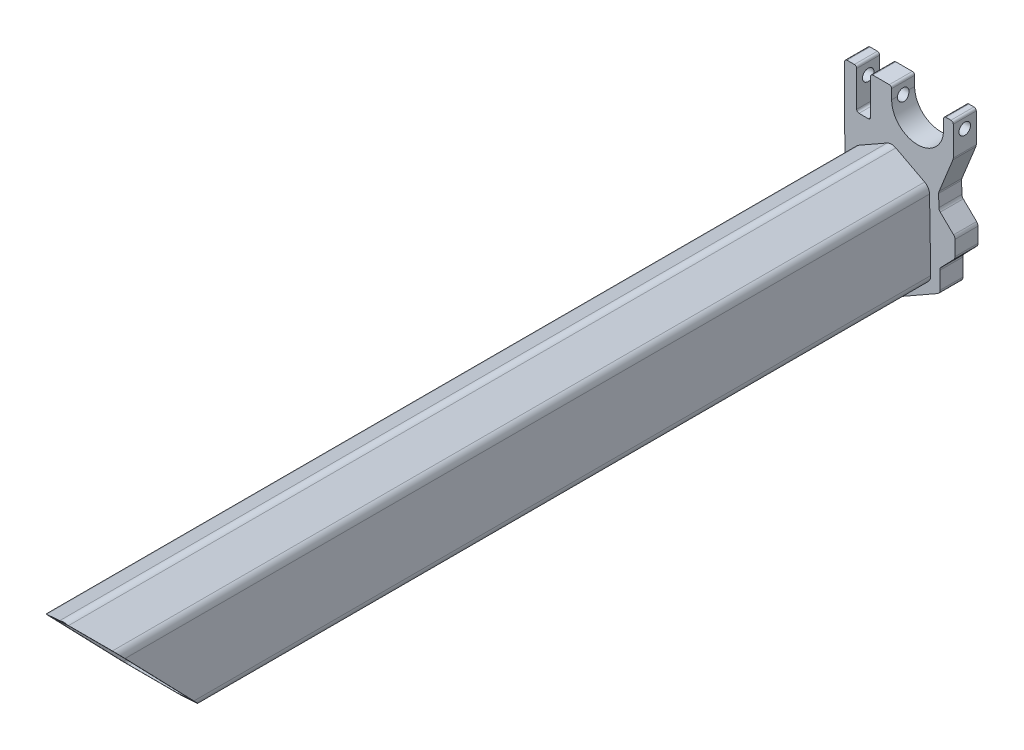
from build123d import *

# Parameters (mm, degrees)
BOSS_EXTRUDE1_DEPTH     = 5
BOSS_EXTRUDE2_DEPTH     = 180
SKETCH3_R               = 1.25
CUT_EXTRUDE1_DEPTH      = 180
CUT_EXTRUDE1_DEPTH_BACK = 180


with BuildPart() as part:
    # Sketch1 → Boss-Extrude1 (new body)
    with BuildSketch(Plane.XY):
        with BuildLine():
            Line((176.569505492, 187.840095713), (176.899877953, 168.242969935))
            ThreePointArc((176.899877953, 168.242969935), (177.048290864, 167.735381874), (177.434829134, 167.374466097))
            Line((177.434829134, 167.374466097), (186.718316852, 162.499660601))
            ThreePointArc((186.718316852, 162.499660601), (187.200079416, 162.385162323), (187.67770885, 162.515834233))
            Line((187.67770885, 162.515834233), (196.791607056, 167.700786723))
            ThreePointArc((196.791607056, 167.700786723), (197.16576035, 168.074526398), (197.296979738, 168.586828559))
            Line((197.296979738, 168.586828559), (197.234516514, 172.292039484))
            ThreePointArc((197.234516514, 172.292039484), (197.304175726, 172.675951622), (197.515449261, 173.003982761))
            Line((197.515449261, 173.003982761), (200.266782587, 175.849671866))
            ThreePointArc((200.266782587, 175.849671866), (200.474929456, 176.169876136), (200.547857403, 176.544759328))
            Line((200.547857403, 176.544759328), (200.547857403, 179.779238985))
            ThreePointArc((200.547857403, 179.779238985), (200.468478786, 180.169695473), (200.242944865, 180.498164169))
            Line((200.242944865, 180.498164169), (197.341824739, 183.303090564))
            ThreePointArc((197.341824739, 183.303090564), (197.119614365, 183.623813941), (197.037054271, 184.005159933))
            Line((197.037054271, 184.005159933), (196.992324343, 186.658462241))
            ThreePointArc((196.992324343, 186.658462241), (197.009048268, 186.858204702), (197.065271311, 187.050599374))
            Line((197.065271311, 187.050599374), (200.096416454, 194.537254131))
            ThreePointArc((200.096416454, 194.537254131), (200.151063173, 194.721369242), (200.169505492, 194.912535449))
            Line((200.169505492, 194.912535449), (200.169505492, 201.285162323))
            ThreePointArc((200.169505492, 201.285162323), (200.023058882, 201.638715714), (199.669505492, 201.785162323))
            Line((199.669505492, 201.785162323), (198.569505492, 201.785162323))
            ThreePointArc((198.569505492, 201.785162323), (198.215952101, 201.638715714), (198.069505492, 201.285162323))
            Line((198.069505492, 201.285162323), (198.069505492, 199.185162323))
            ThreePointArc((198.069505492, 199.185162323), (192.419505492, 193.535162323), (186.769505492, 199.185162323))
            Line((186.769505492, 199.185162323), (186.769505492, 201.285162323))
            ThreePointArc((186.769505492, 201.285162323), (186.623058882, 201.638715714), (186.269505492, 201.785162323))
            Line((186.269505492, 201.785162323), (182.669505492, 201.785162323))
            ThreePointArc((182.669505492, 201.785162323), (182.315952101, 201.638715714), (182.169505492, 201.285162323))
            Line((182.169505492, 201.285162323), (182.169505492, 193.585162323))
            ThreePointArc((182.169505492, 193.585162323), (182.023058882, 193.231608933), (181.669505492, 193.085162323))
            Line((181.669505492, 193.085162323), (179.669505492, 193.085162323))
            ThreePointArc((179.669505492, 193.085162323), (179.315952101, 193.231608933), (179.169505492, 193.585162323))
            Line((179.169505492, 193.585162323), (179.169505492, 201.285162323))
            ThreePointArc((179.169505492, 201.285162323), (179.023058882, 201.638715714), (178.669505492, 201.785162323))
            Line((178.669505492, 201.785162323), (177.069505492, 201.785162323))
            ThreePointArc((177.069505492, 201.785162323), (176.715952101, 201.638715714), (176.569505492, 201.285162323))
            Line((176.569505492, 201.285162323), (176.569505492, 187.840095713))
        make_face()
        with BuildLine():
            Line((186.260276974, 189.669797845), (180.118302096, 186.175590732))
            ThreePointArc((180.118302096, 186.175590732), (179.744148802, 185.801851058), (179.612929414, 185.289548897))
            Line((179.612929414, 185.289548897), (179.869468758, 170.072076543))
            ThreePointArc((179.869468758, 170.072076543), (180.017881669, 169.564488482), (180.404419939, 169.203572705))
            Line((180.404419939, 169.203572705), (186.660683401, 165.918377698))
            ThreePointArc((186.660683401, 165.918377698), (187.142445966, 165.803879419), (187.6200754, 165.934551329))
            Line((187.6200754, 165.934551329), (193.762050278, 169.428758442))
            ThreePointArc((193.762050278, 169.428758442), (194.136203572, 169.802498117), (194.26742296, 170.314800278))
            Line((194.26742296, 170.314800278), (194.010883616, 185.532272632))
            ThreePointArc((194.010883616, 185.532272632), (193.862470704, 186.039860693), (193.475932435, 186.400776469))
            Line((193.475932435, 186.400776469), (187.219668972, 189.685971477))
            ThreePointArc((187.219668972, 189.685971477), (186.737906408, 189.800469755), (186.260276974, 189.669797845))
        make_face(mode=Mode.SUBTRACT)
    extrude(amount=BOSS_EXTRUDE1_DEPTH)

    # Sketch2 → Boss-Extrude2 (add)
    with BuildSketch(Plane.XY.offset(5)):
        with BuildLine():
            Line((185.765791725, 190.538983866), (179.623816847, 187.044776753))
            ThreePointArc((179.623816847, 187.044776753), (178.875510259, 186.297297404), (178.613071484, 185.272693082))
            Line((178.613071484, 185.272693082), (178.869610827, 170.055220728))
            ThreePointArc((178.869610827, 170.055220728), (179.16643665, 169.040044606), (179.93951319, 168.318213053))
            Line((179.93951319, 168.318213053), (186.195776652, 165.033018045))
            ThreePointArc((186.195776652, 165.033018045), (187.159301781, 164.804021489), (188.114560649, 165.065365309))
            Line((188.114560649, 165.065365309), (194.256535527, 168.559572421))
            ThreePointArc((194.256535527, 168.559572421), (195.004842115, 169.307051771), (195.26728089, 170.331656093))
            Line((195.26728089, 170.331656093), (195.010741546, 185.549128447))
            ThreePointArc((195.010741546, 185.549128447), (194.713915724, 186.564304569), (193.940839184, 187.286136122))
            Line((193.940839184, 187.286136122), (187.684575722, 190.57133113))
            ThreePointArc((187.684575722, 190.57133113), (186.721050593, 190.800327686), (185.765791725, 190.538983866))
        make_face()
        with BuildLine():
            Line((186.260276974, 189.669797845), (180.118302096, 186.175590732))
            ThreePointArc((180.118302096, 186.175590732), (179.744148802, 185.801851058), (179.612929414, 185.289548897))
            Line((179.612929414, 185.289548897), (179.869468758, 170.072076543))
            ThreePointArc((179.869468758, 170.072076543), (180.017881669, 169.564488482), (180.404419939, 169.203572705))
            Line((180.404419939, 169.203572705), (186.660683401, 165.918377698))
            ThreePointArc((186.660683401, 165.918377698), (187.142445966, 165.803879419), (187.6200754, 165.934551329))
            Line((187.6200754, 165.934551329), (193.762050278, 169.428758442))
            ThreePointArc((193.762050278, 169.428758442), (194.136203572, 169.802498117), (194.26742296, 170.314800278))
            Line((194.26742296, 170.314800278), (194.010883616, 185.532272632))
            ThreePointArc((194.010883616, 185.532272632), (193.862470704, 186.039860693), (193.475932435, 186.400776469))
            Line((193.475932435, 186.400776469), (187.219668972, 189.685971477))
            ThreePointArc((187.219668972, 189.685971477), (186.737906408, 189.800469755), (186.260276974, 189.669797845))
        make_face(mode=Mode.SUBTRACT)
    extrude(amount=BOSS_EXTRUDE2_DEPTH)

    # Sketch3 → Cut-Extrude1 (cut, two sides)
    with BuildSketch(Plane(origin=(181.684802759, 3.06288055, 0), x_dir=(0, 0, 1), z_dir=(-0.999857931, -0.016855815, 0))) as cut_extrude1_sk:
        with Locations((2.5, 195.771915061)):
            Circle(SKETCH3_R)
        Polygon((185, 187.503282827), (185, 161.625885339), (160, 161.625885339), align=None)
    extrude(amount=CUT_EXTRUDE1_DEPTH, mode=Mode.SUBTRACT)
    extrude(cut_extrude1_sk.sketch, amount=-CUT_EXTRUDE1_DEPTH_BACK, mode=Mode.SUBTRACT)


solid = part.part
